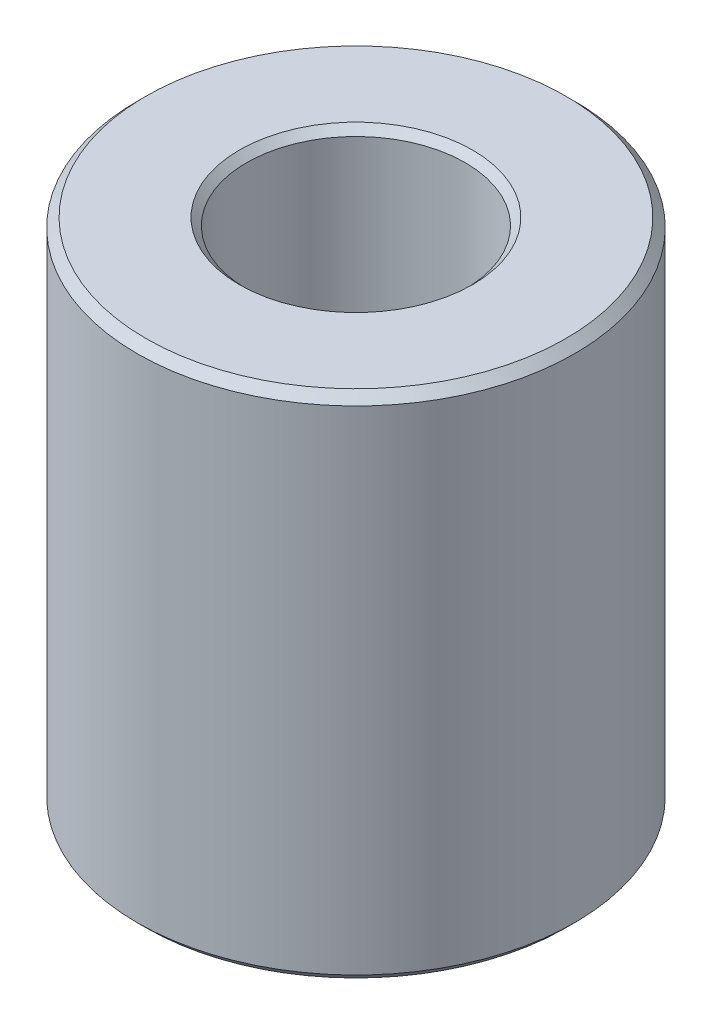
from build123d import *

# Parameters (mm, degrees)
SKETCH1_R                             = 19.05
EXTRUDE1_DEPTH                        = 44.45
CHAMFER1_SIZE                         = 0.762
F_3_4_0_75_DIAMETER_HOLE1_D           = 19.05
F_3_4_0_75_DIAMETER_HOLE1_DEPTH       = 36.068
F_3_4_0_75_DIAMETER_HOLE1_CSINK_D     = 20.32
F_3_4_0_75_DIAMETER_HOLE1_CSINK_ANGLE = 90
CHAMFER2_SIZE                         = 0.254


with BuildPart() as part:
    # Sketch1 → Extrude1 (new body)
    with BuildSketch(Plane(origin=(0, 0, 0), x_dir=(1, 0, 0), z_dir=(0, 1, 0))):
        with Locations(Location((0, 0, 0), (0, 0, 270))):  # turned: the seam where the file's is
            Circle(SKETCH1_R)
    extrude(amount=EXTRUDE1_DEPTH)

    # Sketch2 → 3/8 (0.375) Diameter Hole1 (revolve, cut)
    with BuildSketch(Plane(origin=(0, 44.45, 0), x_dir=(0, 0, 1), z_dir=(1, 0, 0))):
        Polygon((0, 0), (0, 44.45), (5.4102, 44.45), (4.7752, 43.815), (4.7752, 0), align=None)
    revolve(axis=Axis((0, 50.8, 0), (0, -1, 0)), mode=Mode.SUBTRACT)

    # Chamfer1
    chamfer1_edges = [part.edges().sort_by_distance(p)[0] for p in [
        (0, 0, -19.05),
        (0, 44.45, -19.05),
    ]]
    chamfer(chamfer1_edges, length=CHAMFER1_SIZE)

    # 3/4 (0.75) Diameter Hole1
    with Locations(Plane(origin=(0, 44.45, 0), x_dir=(-1, 0, 0), z_dir=(0, 1, 0))):
        with Locations((0, 0)):
            CounterSinkHole(F_3_4_0_75_DIAMETER_HOLE1_D / 2, F_3_4_0_75_DIAMETER_HOLE1_CSINK_D / 2, depth=F_3_4_0_75_DIAMETER_HOLE1_DEPTH, counter_sink_angle=F_3_4_0_75_DIAMETER_HOLE1_CSINK_ANGLE)

    # Chamfer2
    chamfer2_edges = [part.edges().sort_by_distance(p)[0] for p in [
        (-9.525, 8.382, 0),
    ]]
    chamfer(chamfer2_edges, length=CHAMFER2_SIZE)


solid = part.part
